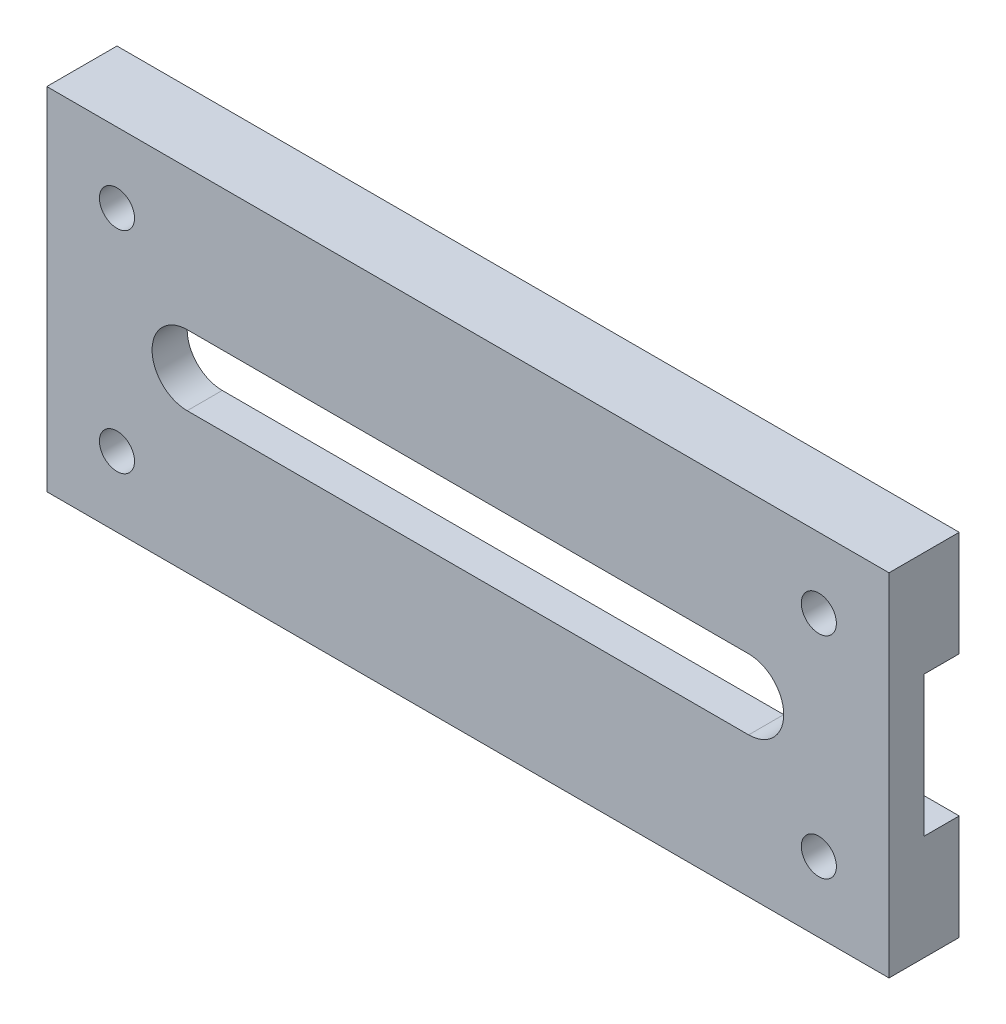
from build123d import *

# Parameters (mm, degrees)
SKETCH1_W           = 152.4
SKETCH1_H           = 63.5
SKETCH1_R           = 3.175
BOSS_EXTRUDE1_DEPTH = 12.7
SKETCH2_W           = 12.7
SKETCH2_H           = 25.4
CUT_EXTRUDE1_DEPTH  = 153.4


with BuildPart() as part:
    # Sketch1 → Boss-Extrude1 (new body)
    with BuildSketch(Plane.XY):
        Rectangle(SKETCH1_W, SKETCH1_H)
        with Locations((-63.5, 19.05)):
            Circle(SKETCH1_R, mode=Mode.SUBTRACT)
        with Locations((63.5, 19.05)):
            Circle(SKETCH1_R, mode=Mode.SUBTRACT)
        with Locations((63.5, -19.05)):
            Circle(SKETCH1_R, mode=Mode.SUBTRACT)
        with Locations((-63.5, -19.05)):
            Circle(SKETCH1_R, mode=Mode.SUBTRACT)
        with BuildLine():
            Line((-50.8, 6.35), (50.8, 6.35))
            ThreePointArc((50.8, 6.35), (57.15, 0), (50.8, -6.35))
            Line((50.8, -6.35), (-50.8, -6.35))
            ThreePointArc((-50.8, -6.35), (-57.15, 0), (-50.8, 6.35))
        make_face(mode=Mode.SUBTRACT)
    extrude(amount=BOSS_EXTRUDE1_DEPTH)

    # Sketch2 → Cut-Extrude1 (cut, through all)
    with BuildSketch(Plane.ZY.offset(76.2)):
        Rectangle(SKETCH2_W, SKETCH2_H)
    extrude(amount=-CUT_EXTRUDE1_DEPTH, mode=Mode.SUBTRACT)


solid = part.part
